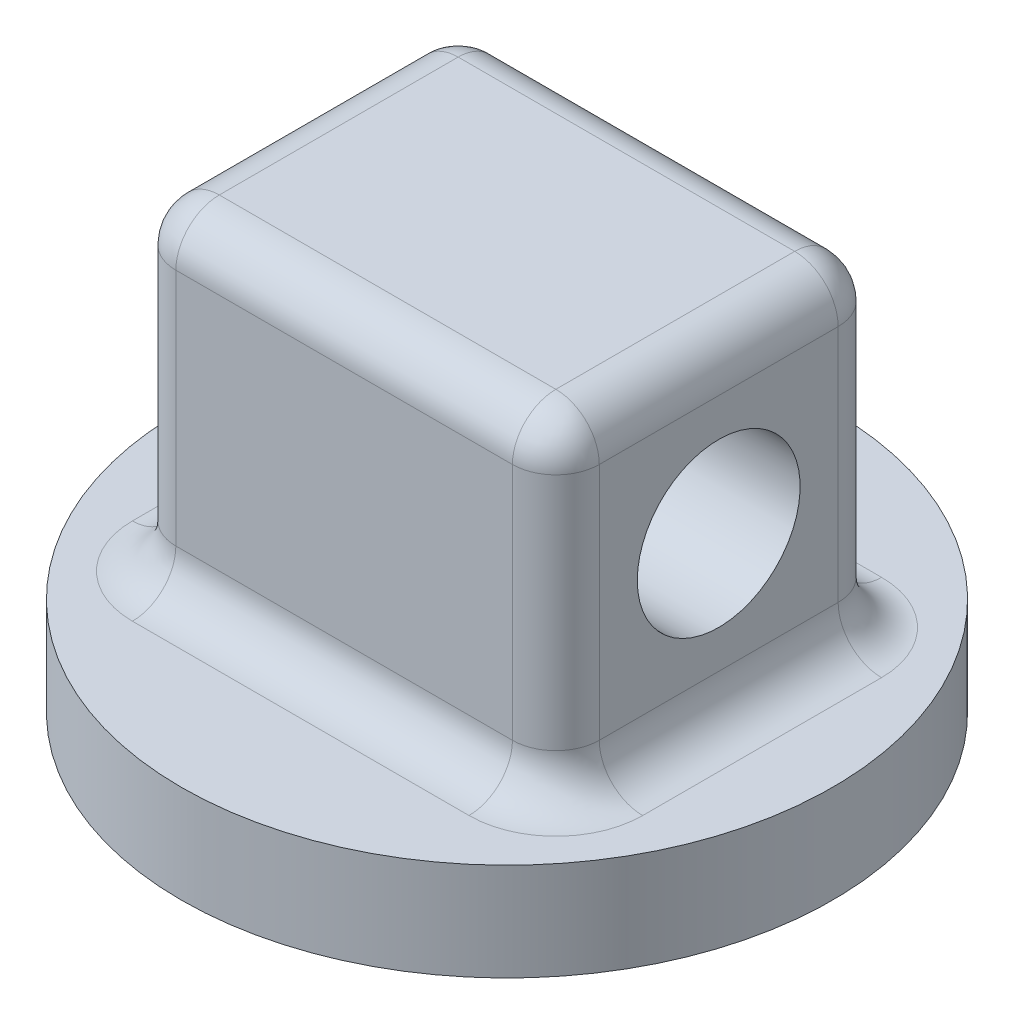
from build123d import *

# Parameters (mm, degrees)
SKETCH1_R               = 25.4
BOSS_EXTRUDE1_DEPTH     = 7.62
SKETCH2_W               = 33.02
SKETCH2_H               = 25.4
BOSS_EXTRUDE2_DEPTH     = 25.4
SKETCH4_R               = 6.35
CUT_EXTRUDE1_DEPTH      = 9.89
CUT_EXTRUDE1_DEPTH_BACK = 42.91
SCALE1_SCALE            = 3
FILLET1_R               = 10.16


with BuildPart() as part:
    # Sketch1 → Boss-Extrude1 (new body)
    with BuildSketch(Plane(origin=(0, 0, 0), x_dir=(1, 0, 0), z_dir=(0, 1, 0))):
        Circle(SKETCH1_R)
    extrude(amount=BOSS_EXTRUDE1_DEPTH)

    # Sketch2 → Boss-Extrude2 (add)
    with BuildSketch(Plane(origin=(0, 7.62, 0), x_dir=(1, 0, 0), z_dir=(0, 1, 0))):
        Rectangle(SKETCH2_W, SKETCH2_H)
    extrude(amount=BOSS_EXTRUDE2_DEPTH)

    # Sketch4 → Cut-Extrude1 (cut, two sides)
    with BuildSketch(Plane.ZY.offset(16.51)) as cut_extrude1_sk:
        with Locations((0, 20.32)):
            Circle(SKETCH4_R)
    extrude(amount=CUT_EXTRUDE1_DEPTH, mode=Mode.SUBTRACT)
    extrude(cut_extrude1_sk.sketch, amount=-CUT_EXTRUDE1_DEPTH_BACK, mode=Mode.SUBTRACT)


with BuildPart() as part_1:
    # Scale1: scaled about (0, 12.489824254, 0)
    add(part.part.scale(SCALE1_SCALE).moved(Location((0, -24.979648508, 0))))

    # Fillet1
    fillet1_edges = [part_1.edges().sort_by_distance(p)[0] for p in [
        (0, 74.080351492, 38.1),
        (49.53, -2.119648508, 0),
        (49.53, 35.980351492, 38.1),
        (0, -2.119648508, -38.1),
        (49.53, 35.980351492, -38.1),
        (-49.53, -2.119648508, 0),
        (-49.53, 35.980351492, -38.1),
        (0, -2.119648508, 38.1),
        (-49.53, 35.980351492, 38.1),
        (49.53, 74.080351492, 0),
        (0, 74.080351492, -38.1),
        (-49.53, 74.080351492, 0),
    ]]
    fillet(fillet1_edges, radius=FILLET1_R)


solid = part_1.part
